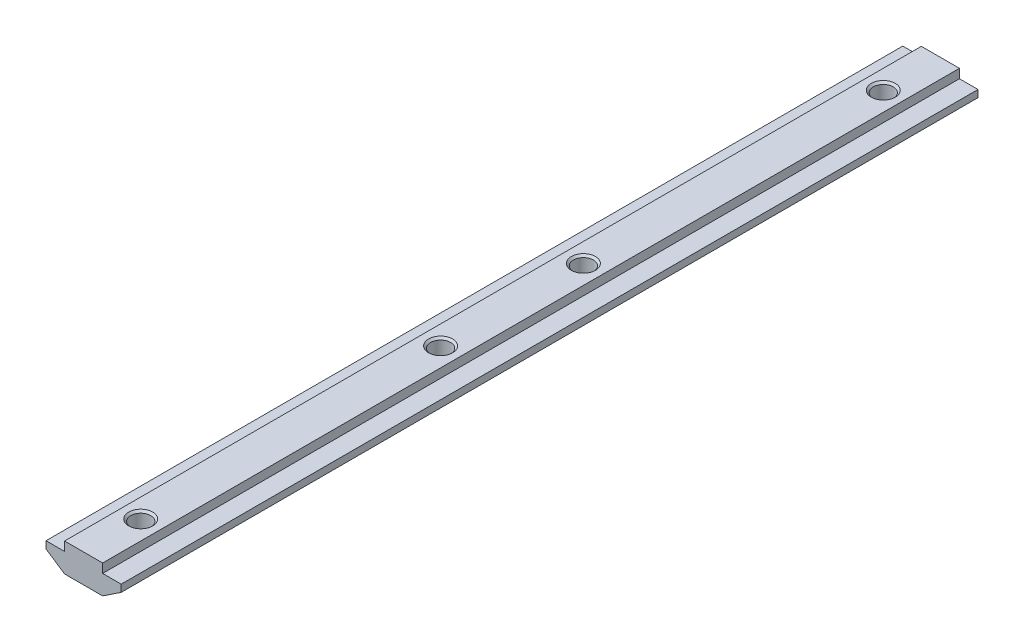
from build123d import *

# Parameters (mm, degrees)
EXTRUDE_1_DEPTH            = 90
HOLE_WIZARD_M52_AT_2_COUNT = 2
HOLE_WIZARD_M52_AT_2_PITCH = 63
HOLE_WIZARD_M52_AT_3_COUNT = 2
HOLE_WIZARD_M52_AT_3_PITCH = 93
HOLE_WIZARD_M52_AT_4_COUNT = 2
HOLE_WIZARD_M52_AT_4_PITCH = 156


with BuildPart() as part:
    # Эскиз1 → Бобышка-Вытянуть1 (new body, symmetric)
    with BuildSketch(Plane.XY):
        Polygon((4, 0), (-4, 0), (-4, -1.9), (-7.9, -1.9), (-7.9, -3.4), (-4, -6), (4, -6), (7.9, -3.4), (7.9, -1.9), (4, -1.9), align=None)
    extrude(amount=EXTRUDE_1_DEPTH, both=True)

    # Эскиз6 → Отверстие обработанное метчиком M52 (revolve, cut)
    with BuildSketch(Plane(origin=(0, 0, -78), x_dir=(0, 0, 1), z_dir=(1, 0, 0))):
        Polygon((0, 0), (0, 6), (2.525, 6), (2.1, 5.575), (2.1, 0.425), (2.525, 0), align=None)
    hole_wizard_m52 = revolve(axis=Axis((0, 6.35, -78), (0, -1, 0)), mode=Mode.SUBTRACT)

    # Отверстие обработанное метчиком M52 at 2: Отверстие обработанное метчиком M52 ×2
    with Locations(*[(0, 0, i * HOLE_WIZARD_M52_AT_2_PITCH) for i in range(1, HOLE_WIZARD_M52_AT_2_COUNT)]):
        add(hole_wizard_m52, mode=Mode.SUBTRACT)

    # Отверстие обработанное метчиком M52 at 3: Отверстие обработанное метчиком M52 ×2
    with Locations(*[(0, 0, i * HOLE_WIZARD_M52_AT_3_PITCH) for i in range(1, HOLE_WIZARD_M52_AT_3_COUNT)]):
        add(hole_wizard_m52, mode=Mode.SUBTRACT)

    # Отверстие обработанное метчиком M52 at 4: Отверстие обработанное метчиком M52 ×2
    with Locations(*[(0, 0, i * HOLE_WIZARD_M52_AT_4_PITCH) for i in range(1, HOLE_WIZARD_M52_AT_4_COUNT)]):
        add(hole_wizard_m52, mode=Mode.SUBTRACT)


solid = part.part
